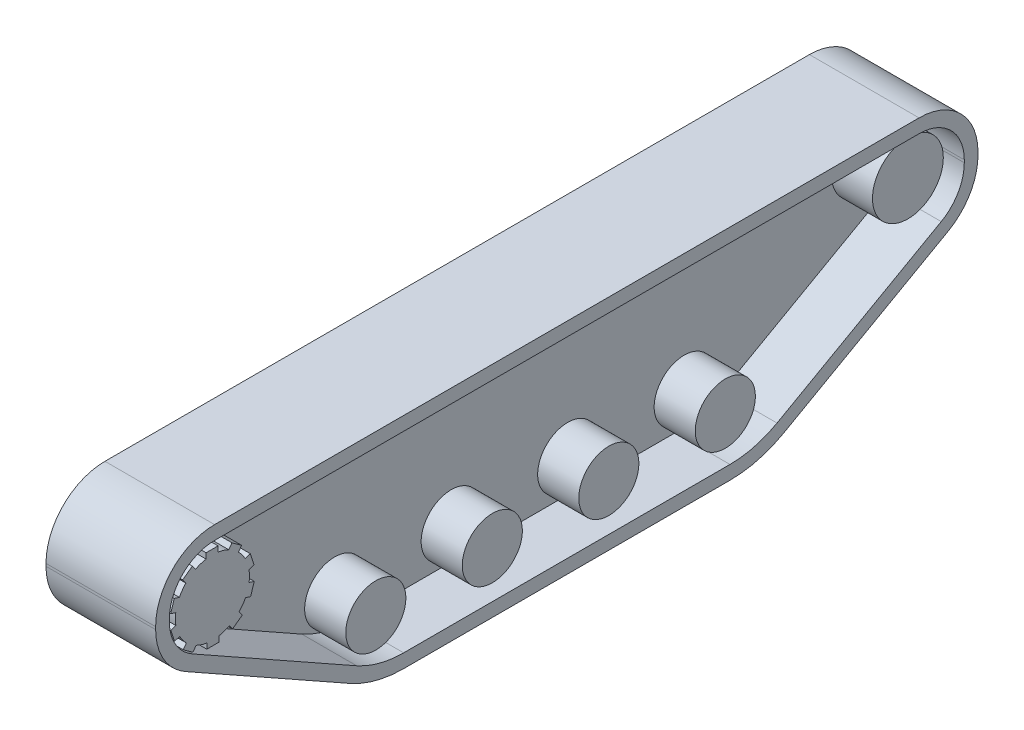
from build123d import *

# Parameters (mm, degrees)
EXTRUDE_1_DEPTH     = 80
CUT_EXTRUDE_1_DEPTH = 40
EXTRUDE_2_DEPTH     = 40
SKETCH_5_R          = 21.930814163
SKETCH_5_R_2        = 25.847454044
EXTRUDE_3_DEPTH     = 30
SKETCH_6_R          = 10
EXTRUDE_4_DEPTH     = 20


with BuildPart() as part:
    # 草图2 → 凸台-拉伸1 (new body)
    with BuildSketch(Plane(origin=(0, 0, 0), x_dir=(0, 0, -1), z_dir=(1, 0, 0))):
        with BuildLine():
            Line((158.264812498, -105.800263885), (278.081233304, -38.403527181))
            ThreePointArc((278.081233304, -38.403527181), (294.118007975, -22.634152676), (300, -0.925779085))
            Line((300, -0.925779085), (300, 0.925779085))
            ThreePointArc((300, 0.925779085), (287.405591591, 31.331370676), (257, 43.925779085))
            Line((257, 43.925779085), (-257, 43.925779085))
            ThreePointArc((-257, 43.925779085), (-287.405591591, 31.331370676), (-300, 0.925779085))
            Line((-300, 0.925779085), (-300, -0.925779085))
            ThreePointArc((-300, -0.925779085), (-294.118007975, -22.634152676), (-278.081233304, -38.403527181))
            Line((-278.081233304, -38.403527181), (-158.264812498, -105.800263885))
            ThreePointArc((-158.264812498, -105.800263885), (-139.316019316, -113.463120111), (-119.043913327, -116.074220915))
            Line((-119.043913327, -116.074220915), (119.043913327, -116.074220915))
            ThreePointArc((119.043913327, -116.074220915), (139.316019316, -113.463120111), (158.264812498, -105.800263885))
        make_face()
    extrude(amount=EXTRUDE_1_DEPTH)

    # 草图3 → 切除-拉伸1 (cut)
    with BuildSketch(Plane(origin=(80, 0, 0), x_dir=(0, 0, -1), z_dir=(1, 0, 0))):
        with BuildLine():
            Line((257, 33.925779085), (-257, 33.925779085))
            ThreePointArc((-257, 33.925779085), (-280.334523779, 24.260302864), (-290, 0.925779085))
            Line((-290, 0.925779085), (-290, -0.925779085))
            ThreePointArc((-290, -0.925779085), (-285.485913097, -17.585693701), (-273.178620908, -29.68777181))
            Line((-273.178620908, -29.68777181), (-153.362200102, -97.084508514))
            ThreePointArc((-153.362200102, -97.084508514), (-136.782006067, -103.789507712), (-119.043913327, -106.074220915))
            Line((-119.043913327, -106.074220915), (119.043913327, -106.074220915))
            ThreePointArc((119.043913327, -106.074220915), (136.782006067, -103.789507712), (153.362200102, -97.084508514))
            Line((153.362200102, -97.084508514), (273.178620908, -29.68777181))
            ThreePointArc((273.178620908, -29.68777181), (285.485913097, -17.585693701), (290, -0.925779085))
            Line((290, -0.925779085), (290, 0.925779085))
            ThreePointArc((290, 0.925779085), (280.334523779, 24.260302864), (257, 33.925779085))
        make_face()
    extrude(amount=-CUT_EXTRUDE_1_DEPTH, mode=Mode.SUBTRACT)

    # 草图4 → 凸台-拉伸2 (add)
    with BuildSketch(Plane(origin=(40, 0, 0), x_dir=(0, 0, -1), z_dir=(1, 0, 0))):
        with BuildLine():
            Line((-237.264786543, 20.974123526), (-239.546765639, 17.833248756))
            ThreePointArc((-239.546765639, 17.833248756), (-236.865961455, 14.739716181), (-234.683185749, 11.276748513))
            Line((-234.683185749, 11.276748513), (-230.908435146, 12.503239332))
            Line((-230.908435146, 12.503239332), (-228.206060722, 4.186186056))
            Line((-228.206060722, 4.186186056), (-231.89838046, 2.986478649))
            ThreePointArc((-231.89838046, 2.986478649), (-231.547897142, -1.09197894), (-231.817475826, -5.176582004))
            Line((-231.817475826, -5.176582004), (-228.042725222, -6.403072824))
            Line((-228.042725222, -6.403072824), (-230.745099646, -14.720126099))
            Line((-230.745099646, -14.720126099), (-234.437419384, -13.520418692))
            ThreePointArc((-234.437419384, -13.520418692), (-236.551129646, -17.025969117), (-239.170092825, -20.172028037))
            Line((-239.170092825, -20.172028037), (-236.837168653, -23.383022689))
            Line((-236.837168653, -23.383022689), (-243.912076745, -28.5232443))
            Line((-243.912076745, -28.5232443), (-246.194055841, -25.38236953))
            ThreePointArc((-246.194055841, -25.38236953), (-249.964594205, -26.976011679), (-253.932586961, -27.981838877))
            Line((-253.932586961, -27.981838877), (-253.932586961, -31.950846543))
            Line((-253.932586961, -31.950846543), (-262.677654297, -31.950846543))
            Line((-262.677654297, -31.950846543), (-262.677654297, -28.068511818))
            ThreePointArc((-262.677654297, -28.068511818), (-266.664803265, -27.141528556), (-270.466187231, -25.62293223))
            Line((-270.466187231, -25.62293223), (-272.799111403, -28.833926882))
            Line((-272.799111403, -28.833926882), (-279.874019495, -23.693705272))
            Line((-279.874019495, -23.693705272), (-277.592040399, -20.552830502))
            ThreePointArc((-277.592040399, -20.552830502), (-280.272844583, -17.459297927), (-282.455620289, -13.996330258))
            Line((-282.455620289, -13.996330258), (-286.230370892, -15.222821078))
            Line((-286.230370892, -15.222821078), (-288.932745316, -6.905767802))
            Line((-288.932745316, -6.905767802), (-285.240425578, -5.706060395))
            ThreePointArc((-285.240425578, -5.706060395), (-285.590908896, -1.627602806), (-285.321330213, 2.457000258))
            Line((-285.321330213, 2.457000258), (-289.096080816, 3.683491078))
            Line((-289.096080816, 3.683491078), (-286.393706392, 12.000544353))
            Line((-286.393706392, 12.000544353), (-282.701386654, 10.800836946))
            ThreePointArc((-282.701386654, 10.800836946), (-280.587676392, 14.306387371), (-277.968713213, 17.452446291))
            Line((-277.968713213, 17.452446291), (-280.301637385, 20.663440943))
            Line((-280.301637385, 20.663440943), (-273.226729293, 25.803662554))
            Line((-273.226729293, 25.803662554), (-270.944750197, 22.662787784))
            ThreePointArc((-270.944750197, 22.662787784), (-267.174211833, 24.256429933), (-263.206219077, 25.262257132))
            Line((-263.206219077, 25.262257132), (-263.206219077, 29.231264797))
            Line((-263.206219077, 29.231264797), (-254.461151741, 29.231264797))
            Line((-254.461151741, 29.231264797), (-254.461151741, 25.348930073))
            ThreePointArc((-254.461151741, 25.348930073), (-250.474002773, 24.42194681), (-246.672618807, 22.903350484))
            Line((-246.672618807, 22.903350484), (-244.339694635, 26.114345136))
            Line((-244.339694635, 26.114345136), (-237.264786543, 20.974123526))
        make_face()
    extrude(amount=EXTRUDE_2_DEPTH)

    # 草图5 → 凸台-拉伸3 (add)
    with BuildSketch(Plane(origin=(40, 0, 0), x_dir=(0, 0, -1), z_dir=(1, 0, 0))):
        with Locations((-129.354117612, -82.245801831)):
            Circle(SKETCH_5_R)
        with Locations((-44.354117612, -82.245801831)):
            Circle(SKETCH_5_R)
        with Locations((40.645882388, -82.245801831)):
            Circle(SKETCH_5_R)
        with Locations((125.645882388, -82.245801831)):
            Circle(SKETCH_5_R)
        with Locations((258.847706699, 0)):
            Circle(SKETCH_5_R_2)
    extrude(amount=EXTRUDE_3_DEPTH)

    # 草图6 → 凸台-拉伸4 (add)
    with BuildSketch(Plane.ZY):
        with Locations((-180, -16.074220915)):
            Circle(SKETCH_6_R)
        with Locations((180, -16.074220915)):
            Circle(SKETCH_6_R)
    extrude(amount=EXTRUDE_4_DEPTH)


solid = part.part
